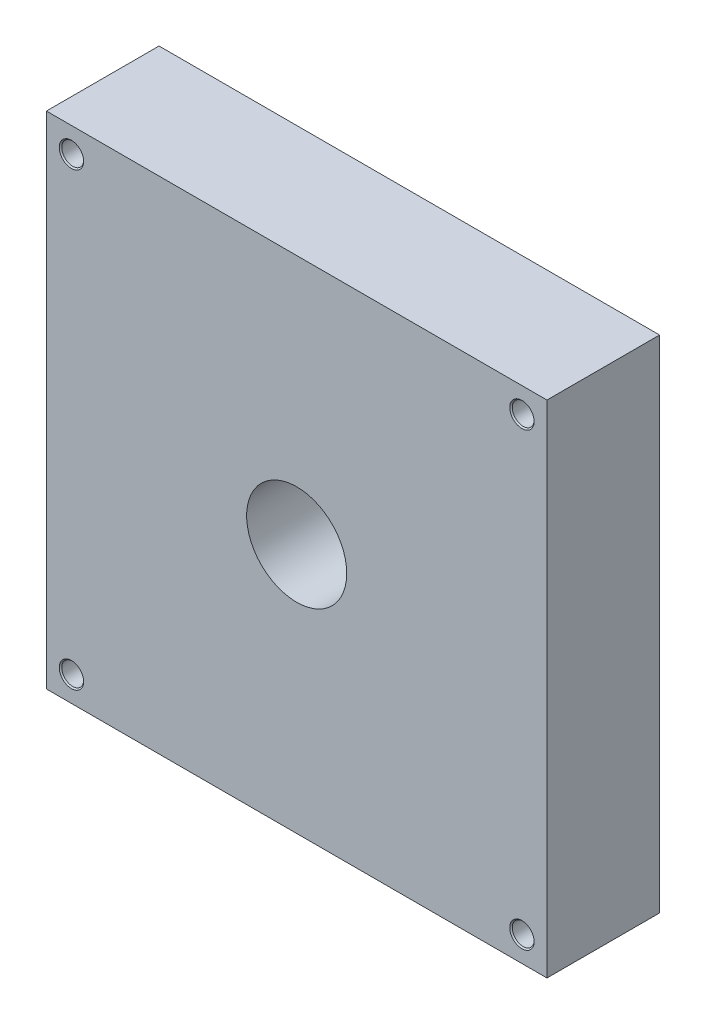
from build123d import *

# Parameters (mm, degrees)
SKETCH1_W                                     = 254
SKETCH1_H                                     = 254
SKETCH1_R                                     = 25.4
BOSS_EXTRUDE1_DEPTH                           = 57.15
CBORE_FOR_1_4_SOCKET_HEAD_CAP_SCREW2_AT_COUNT = 2
CBORE_FOR_1_4_SOCKET_HEAD_CAP_SCREW2_AT_PITCH = 228.6
CBORE_FOR_1_4_SOCKET_HEAD_CAP_SCREW2_2_COUNT  = 2
CBORE_FOR_1_4_SOCKET_HEAD_CAP_SCREW2_2_PITCH  = 323.289220358
CBORE_FOR_1_4_SOCKET_HEAD_CAP_SCREW2_3_COUNT  = 2
CBORE_FOR_1_4_SOCKET_HEAD_CAP_SCREW2_3_PITCH  = 228.6
F_10_32_TAPPED_HOLE1_D                        = 4.0386
F_10_32_TAPPED_HOLE1_DEPTH                    = 19.05
F_10_32_TAPPED_HOLE1_TIP                      = 1.213317848


with BuildPart() as part:
    # Sketch1 → Boss-Extrude1 (new body)
    with BuildSketch(Plane.XY):
        Rectangle(SKETCH1_W, SKETCH1_H)
        Circle(SKETCH1_R, mode=Mode.SUBTRACT)
    extrude(amount=-BOSS_EXTRUDE1_DEPTH)

    # Sketch3 → CBORE for 1/4 Socket Head Cap Screw2 (revolve, cut)
    with BuildSketch(Plane(origin=(-114.3, 114.3, 0), x_dir=(0, -1, 0), z_dir=(1, 0, 0))):
        Polygon((0, 0), (0, 57.15), (3.8989, 57.15), (3.2639, 56.515), (3.2639, 50.8), (5.55625, 50.8), (5.55625, 0.635), (6.19125, 0), align=None)
    cbore_for_1_4_socket_head_cap_screw2 = revolve(axis=Axis((-114.3, 114.3, 6.35), (0, 0, -1)), mode=Mode.SUBTRACT)

    # CBORE for 1/4 Socket Head Cap Screw2 at: CBORE for 1/4 Socket Head Cap Screw2 ×2
    with Locations(*[(i * CBORE_FOR_1_4_SOCKET_HEAD_CAP_SCREW2_AT_PITCH, 0, 0) for i in range(1, CBORE_FOR_1_4_SOCKET_HEAD_CAP_SCREW2_AT_COUNT)]):
        add(cbore_for_1_4_socket_head_cap_screw2, mode=Mode.SUBTRACT)

    # CBORE for 1_4 Socket Head Cap Screw2 2: CBORE for 1/4 Socket Head Cap Screw2 ×2
    with Locations(*[Vector(0.707106781, -0.707106781, 0) * (i * CBORE_FOR_1_4_SOCKET_HEAD_CAP_SCREW2_2_PITCH) for i in range(1, CBORE_FOR_1_4_SOCKET_HEAD_CAP_SCREW2_2_COUNT)]):
        add(cbore_for_1_4_socket_head_cap_screw2, mode=Mode.SUBTRACT)

    # CBORE for 1_4 Socket Head Cap Screw2 3: CBORE for 1/4 Socket Head Cap Screw2 ×2
    with Locations(*[(0, -i * CBORE_FOR_1_4_SOCKET_HEAD_CAP_SCREW2_3_PITCH, 0) for i in range(1, CBORE_FOR_1_4_SOCKET_HEAD_CAP_SCREW2_3_COUNT)]):
        add(cbore_for_1_4_socket_head_cap_screw2, mode=Mode.SUBTRACT)

    # #10-32 Tapped Hole1
    with Locations(Plane(origin=(0, -127, 0), x_dir=(-1, 0, 0), z_dir=(0, -1, 0))):
        with Locations((3.175, 25.4), (-9.525, 25.4), (37, 14.2875), (37, 36.5125)):
            Hole(F_10_32_TAPPED_HOLE1_D / 2, depth=F_10_32_TAPPED_HOLE1_DEPTH)
            with Locations((0, 0, -(F_10_32_TAPPED_HOLE1_DEPTH + F_10_32_TAPPED_HOLE1_TIP / 2))):  # 118° drill point
                Cone(0, F_10_32_TAPPED_HOLE1_D / 2, F_10_32_TAPPED_HOLE1_TIP, mode=Mode.SUBTRACT)


solid = part.part
